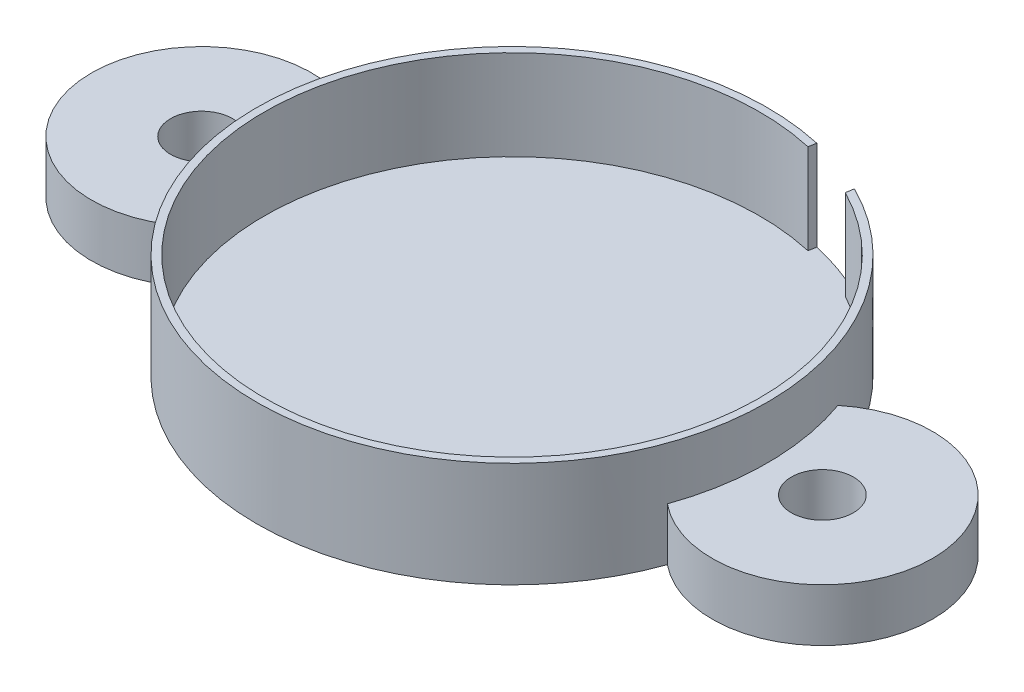
from build123d import *

# Parameters (mm, degrees)
SKETCH1_R           = 53.2765
BOSS_EXTRUDE1_DEPTH = 21.971
SKETCH3_R           = 51.689
CUT_EXTRUDE2_DEPTH  = 18.796
CUT_EXTRUDE7_DEPTH  = 18.796
SKETCH7_R           = 6.477
BOSS_EXTRUDE3_DEPTH = 10.9855


with BuildPart() as part:
    # Sketch1 → Boss-Extrude1 (new body)
    with BuildSketch(Plane(origin=(0, 0, 0), x_dir=(1, 0, 0), z_dir=(0, 1, 0))):
        Circle(SKETCH1_R)
    extrude(amount=BOSS_EXTRUDE1_DEPTH)

    # Sketch3 → Cut-Extrude2 (cut)
    with BuildSketch(Plane(origin=(0, 21.971, 0), x_dir=(1, 0, 0), z_dir=(0, 1, 0))):
        Circle(SKETCH3_R)
    extrude(amount=-CUT_EXTRUDE2_DEPTH, mode=Mode.SUBTRACT)

    # Sketch6 → Cut-Extrude7 (cut)
    with BuildSketch(Plane(origin=(0, 21.971, 0), x_dir=(1, 0, 0), z_dir=(0, 1, 0))):
        with BuildLine():
            Line((23.516654444, 46.029552298), (23.788647289, 47.670595889))
            ThreePointArc((23.788647289, 47.670595889), (17.831858769, 50.203687764), (11.611838625, 51.995679205))
            Line((11.611838625, 51.995679205), (11.333405616, 50.431206987))
            ThreePointArc((11.333405616, 50.431206987), (17.563465277, 48.613551696), (23.516654444, 46.029552298))
        make_face()
    extrude(amount=-CUT_EXTRUDE7_DEPTH, mode=Mode.SUBTRACT)

    # Sketch7 → Boss-Extrude3 (add)
    with BuildSketch(Plane.XZ):
        with BuildLine():
            ThreePointArc((50.217200735, -17.793768644), (87.757, 0), (50.217200735, 17.793768644))
            ThreePointArc((50.217200735, 17.793768644), (53.2765, 0), (50.217200735, -17.793768644))
        make_face()
        with Locations((64.77, 0)):
            Circle(SKETCH7_R, mode=Mode.SUBTRACT)
        with BuildLine():
            ThreePointArc((-50.217200735, 17.793768644), (-87.757, 0), (-50.217200735, -17.793768644))
            ThreePointArc((-50.217200735, -17.793768644), (-53.2765, 0), (-50.217200735, 17.793768644))
        make_face()
        with Locations((-64.77, 0)):
            Circle(SKETCH7_R, mode=Mode.SUBTRACT)
    extrude(amount=-BOSS_EXTRUDE3_DEPTH)


solid = part.part
